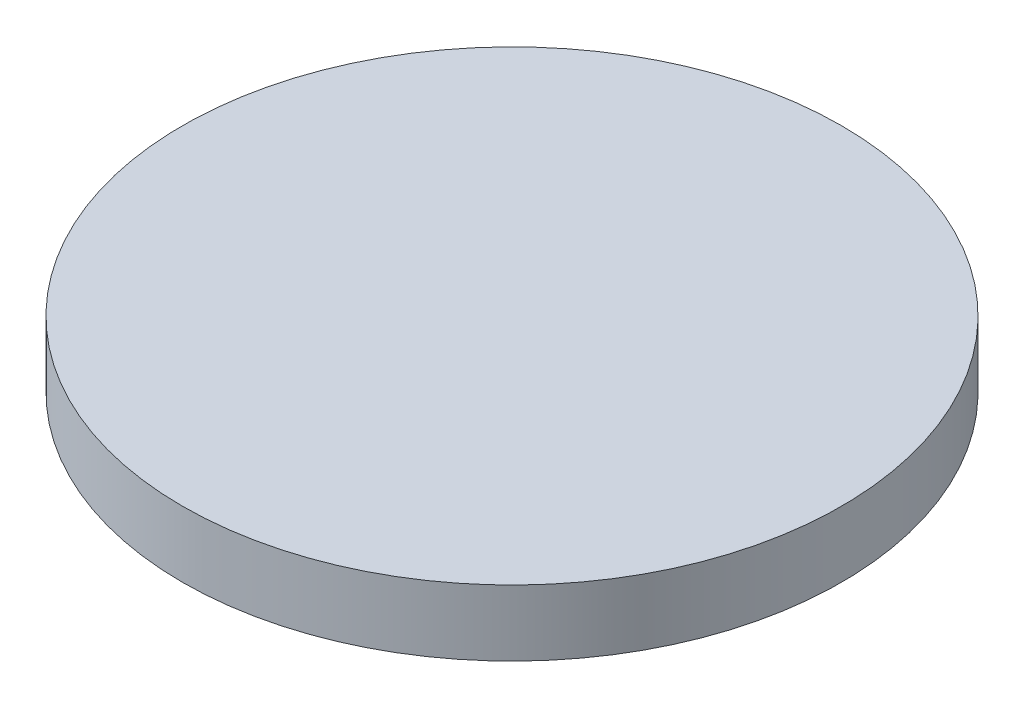
from build123d import *

# Parameters (mm, degrees)
SKETCH1_R           = 40
BOSS_EXTRUDE1_DEPTH = 4


with BuildPart() as part:
    # Sketch1 → Boss-Extrude1 (new body, symmetric)
    with BuildSketch(Plane(origin=(0, 0, 0), x_dir=(1, 0, 0), z_dir=(0, 1, 0))):
        Circle(SKETCH1_R)
    extrude(amount=BOSS_EXTRUDE1_DEPTH, both=True)


solid = part.part
